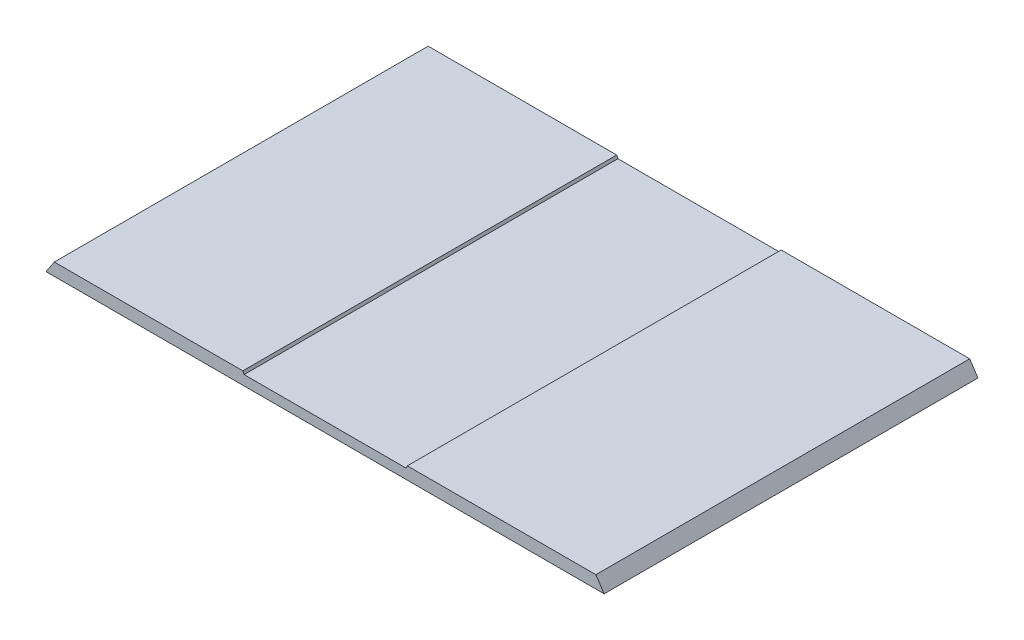
from build123d import *

# Parameters (mm, degrees)
AUFSATZ_LINEAR_AUSTRAGEN1_DEPTH = 450


with BuildPart() as part:
    # Skizze1 → Aufsatz-Linear austragen1 (new body)
    with BuildSketch(Plane.XY):
        Polygon((-325.91423977, -179.367647059), (-335.91423977, -194.367647059), (335.91423977, -194.367647059), (325.91423977, -179.367647059), (99, -179.367647059), (97.5, -182.5), (-97.5, -182.5), (-99, -179.367647059), align=None)
    extrude(amount=AUFSATZ_LINEAR_AUSTRAGEN1_DEPTH)


solid = part.part
